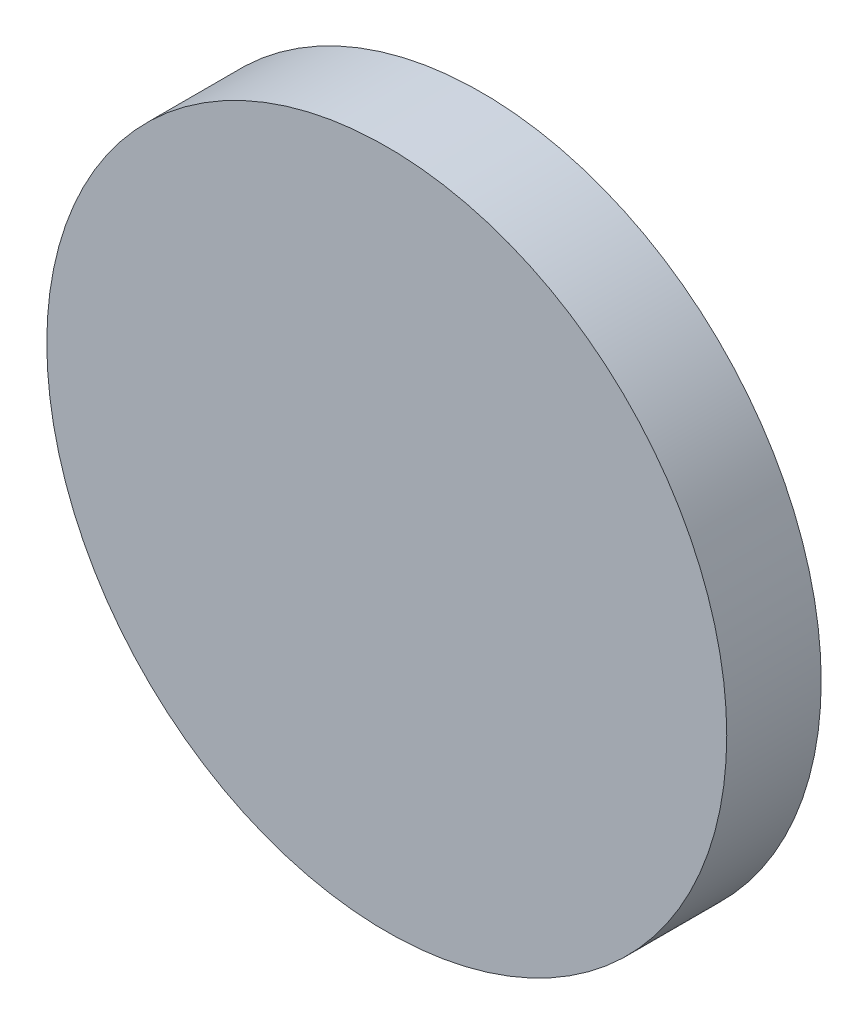
from build123d import *

# Parameters (mm, degrees)
ESQUISSE1_R        = 36
BOSS_EXTRU_1_DEPTH = 10


with BuildPart() as part:
    # Esquisse1 → Boss.-Extru.1 (new body)
    with BuildSketch(Plane.XY):
        Circle(ESQUISSE1_R)
    extrude(amount=BOSS_EXTRU_1_DEPTH)


solid = part.part
